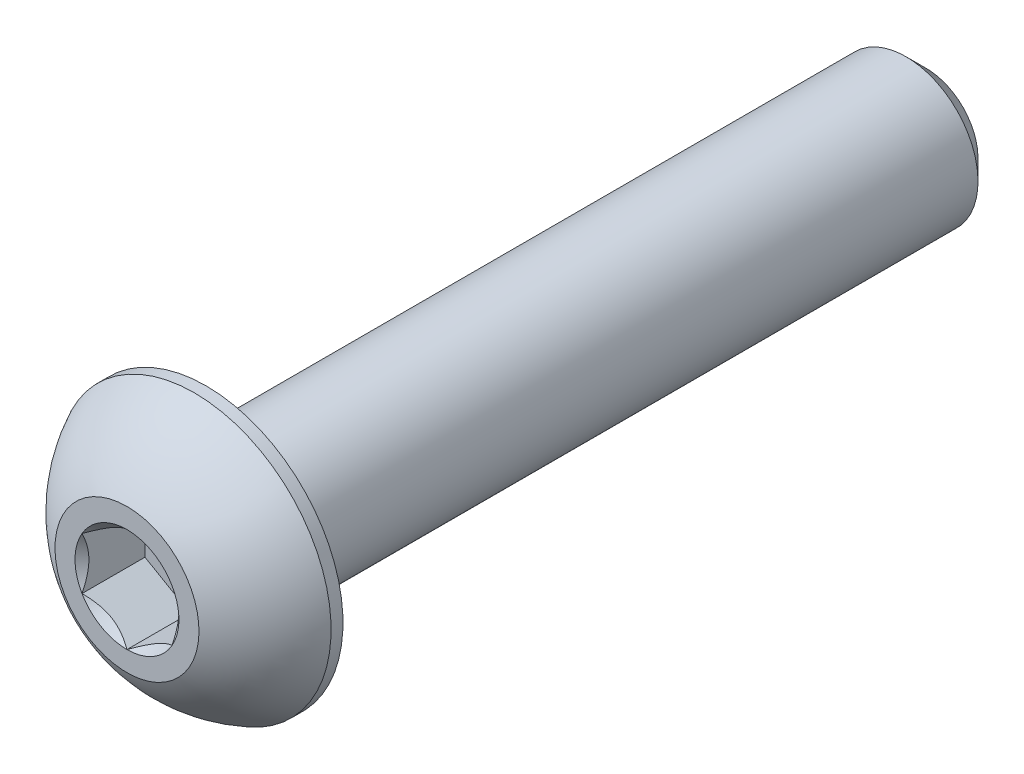
from build123d import *

# Parameters (mm, degrees)
CUT_EXTRUDE1_DEPTH = 1.75


with BuildPart() as part:
    # Sketch2 → Revolve1 (revolve)
    with BuildSketch(Plane(origin=(0, 0, 0), x_dir=(0, 0, -1), z_dir=(1, 0, 0)), mode=Mode.PRIVATE) as revolve1_sk:
        with BuildLine():
            Line((-11.1, 0), (11.1, 0))
            Line((11.1, 0), (11.1, 1.44))
            Line((11.1, 1.44), (10.54, 2))
            Line((10.54, 2), (-8.9, 2))
            Line((-8.9, 2), (-8.9, 3.8))
            Line((-8.9, 3.8), (-9.23, 3.8))
            ThreePointArc((-9.23, 3.8), (-10.306499853, 3.047002626), (-11.1, 2))
            Line((-11.1, 2), (-11.1, 0))
        make_face()
    revolve(revolve1_sk.sketch.rotate(Axis((0, 0, 11.1), (0, 0, -1)), 180), axis=Axis((0, 0, 11.1), (0, 0, -1)))

    # Sketch3 → Cut-Extrude1 (cut)
    with BuildSketch(Plane.XY.offset(11.1)):
        Polygon((0, 1.443375673), (-1.25, 0.721687836), (-1.25, -0.721687836), (0, -1.443375673), (1.25, -0.721687836), (1.25, 0.721687836), align=None)
    extrude(amount=-CUT_EXTRUDE1_DEPTH, mode=Mode.SUBTRACT)

    # Cut-Extrude2 cone 1 section (through the dimple's axis) → Cut-Extrude2 (revolve, cut)
    with BuildSketch(Plane(origin=(0, 0, 11.1), x_dir=(0, -1, 0), z_dir=(1, 0, 0))):
        Polygon((0, 0), (1.443375673, 0), (0, 1.443375673), align=None)
    revolve(axis=Axis((0, 0, 11.1), (0, 0, -1)), mode=Mode.SUBTRACT)


solid = part.part
